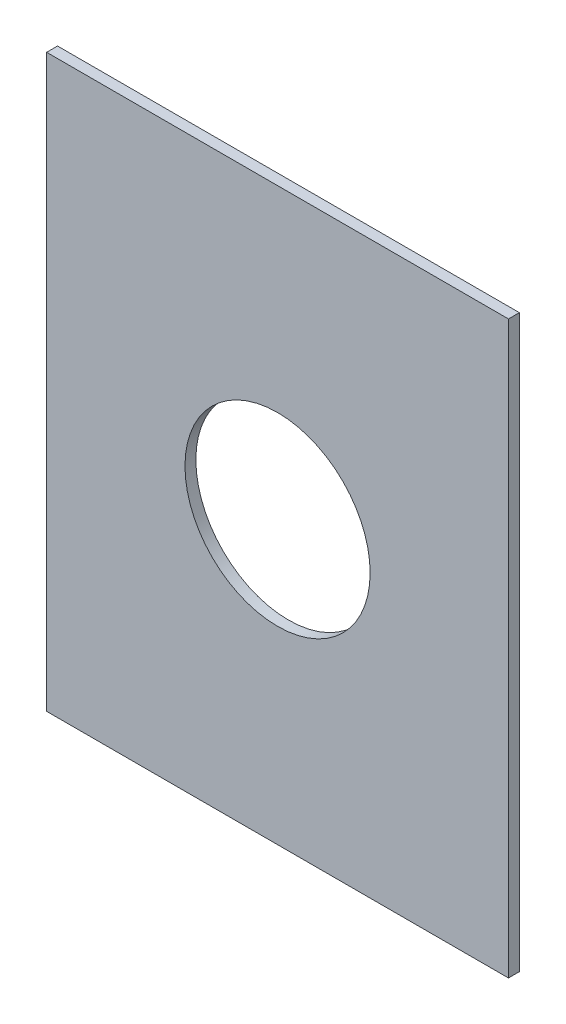
from build123d import *

# Parameters (mm, degrees)
ESQUISSE1_W             = 212
ESQUISSE1_H             = 262
BOSS_EXTRU_1_DEPTH      = 5
ESQUISSE2_R             = 42.5
ENL_V_MAT_EXTRU_1_DEPTH = 6


with BuildPart() as part:
    # Esquisse1 → Boss.-Extru.1 (new body)
    with BuildSketch(Plane.XY):
        with Locations((106, 131)):
            Rectangle(ESQUISSE1_W, ESQUISSE1_H)
    extrude(amount=BOSS_EXTRU_1_DEPTH)

    # Esquisse2 → Enlèv. mat.-Extru.1 (cut, through all)
    with BuildSketch(Plane(origin=(0, 0, 0), x_dir=(-1, 0, 0), z_dir=(0, 0, -1))):
        with Locations((-106, 129.3)):
            Circle(ESQUISSE2_R)
    extrude(amount=-ENL_V_MAT_EXTRU_1_DEPTH, mode=Mode.SUBTRACT)


solid = part.part
